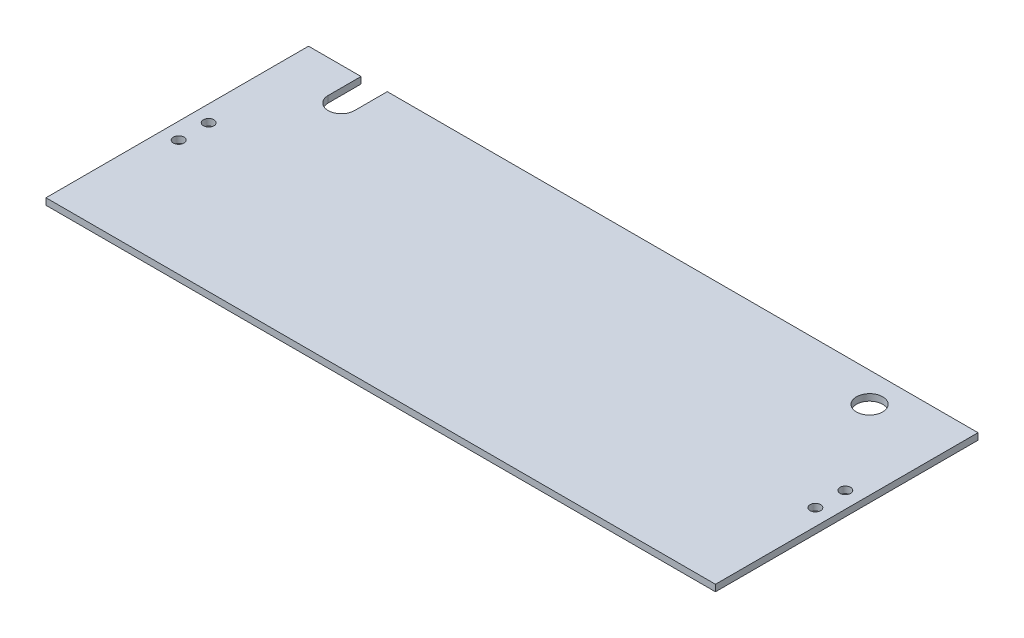
from build123d import *

# Parameters (mm, degrees)
SKETCH1_W              = 323.85
SKETCH1_H              = 127
BOSS_EXTRUDE1_DEPTH    = 3.175
CUT_EXTRUDE1_DEPTH     = 4.175
SKETCH3_R              = 6.35
CUT_EXTRUDE2_DEPTH     = 58.15
F_10_CLEARANCE_HOLE1_D = 5.1054


with BuildPart() as part:
    # Sketch1 → Boss-Extrude1 (new body)
    with BuildSketch(Plane(origin=(0, 0, 0), x_dir=(1, 0, 0), z_dir=(0, 1, 0))):
        with Locations((161.925, 63.5)):
            Rectangle(SKETCH1_W, SKETCH1_H)
    extrude(amount=BOSS_EXTRUDE1_DEPTH)

    # Sketch2 → Cut-Extrude1 (cut, through all)
    with BuildSketch(Plane(origin=(0, 3.175, 0), x_dir=(1, 0, 0), z_dir=(0, 1, 0))):
        with BuildLine():
            Line((25.4, 127), (25.4, 111.125))
            ThreePointArc((25.4, 111.125), (31.75, 104.775), (38.1, 111.125))
            Line((38.1, 111.125), (38.1, 127))
            Line((38.1, 127), (25.4, 127))
        make_face()
    extrude(amount=-CUT_EXTRUDE1_DEPTH, mode=Mode.SUBTRACT)

    # Sketch3 → Cut-Extrude2 (cut, through all)
    with BuildSketch(Plane(origin=(0, -53.975, 0), x_dir=(-1, 0, 0), z_dir=(0, -1, 0))):
        with Locations((-285.75, 112.649)):
            Circle(SKETCH3_R)
    extrude(amount=-CUT_EXTRUDE2_DEPTH, mode=Mode.SUBTRACT)

    # #10 Clearance Hole1 (through all)
    with Locations(Plane(origin=(0, 3.175, 0), x_dir=(1, 0, 0), z_dir=(0, 1, 0))):
        with Locations((315.9125, 56.25), (315.9125, 70.75), (7.9375, 56.25), (7.9375, 70.75)):
            Hole(F_10_CLEARANCE_HOLE1_D / 2)


solid = part.part
